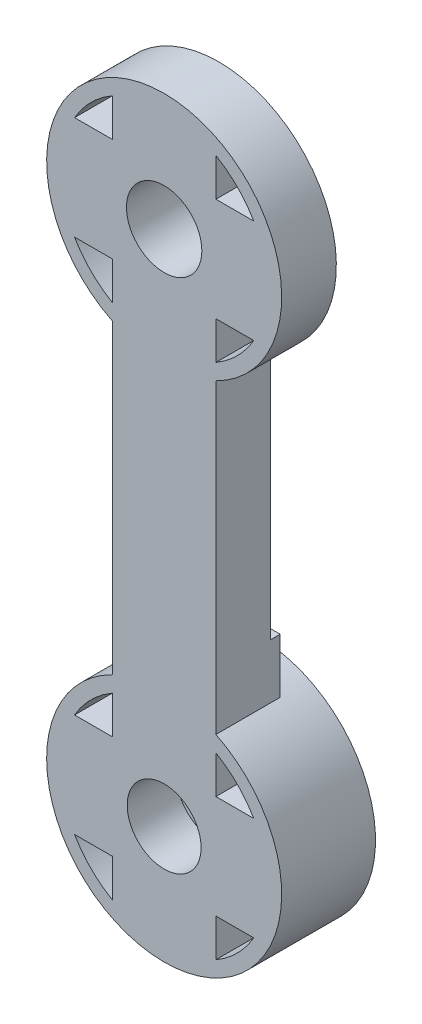
from build123d import *
from build123d.topology import SkipClean

# Parameters (mm, degrees)
SKETCH1_R               = 3.5
SKETCH1_R_2             = 1.5
BOSS_EXTRUDE4_DEPTH     = 3
BOSS_EXTRUDE5_START     = 3
SKETCH3_R               = 1.5
BOSS_EXTRUDE5_DEPTH     = 3
SKETCH4_R               = 2.5
CUT_EXTRUDE1_DEPTH      = 1.5
SKETCH5_R               = 7
CUT_EXTRUDE2_DEPTH      = 2
SKETCH6_R               = 7.95
CUT_EXTRUDE3_DEPTH      = 1
SKETCH7_R               = 2.5
CUT_EXTRUDE4_DEPTH      = 1.85
BOSS_EXTRUDE6_START     = 0.7
SKETCH8_R               = 7.95
SKETCH8_R_2             = 7
BOSS_EXTRUDE6_DEPTH     = 0.7
BOSS_EXTRUDE8_START     = 0.7
SKETCH9_R               = 7.95
SKETCH9_R_2             = 1.5
BOSS_EXTRUDE8_DEPTH     = 0.7
BOSS_EXTRUDE9_START     = 0.7
BOSS_EXTRUDE9_DEPTH     = 0.7
CUT_EXTRUDE5_DEPTH      = 45.603755447
CUT_EXTRUDE5_DEPTH_BACK = 45.603755447
SKETCH11_W              = 3
SKETCH11_H              = 15.9
SKETCH11_W_2            = 2
BOSS_EXTRUDE10_START    = 0.65
BOSS_EXTRUDE10_DEPTH    = 0.65
BOSS_EXTRUDE11_START    = 2.65
SKETCH13_R              = 1.5
BOSS_EXTRUDE11_DEPTH    = 2.65
SKETCH14_R              = 2.55
CUT_EXTRUDE6_DEPTH      = 45.138730158


with BuildPart() as part:
    # Sketch1 → Boss-Extrude4 (new body)
    # profile 1 of 34: a face of its own
    with BuildSketch(Plane.XY):
        with BuildLine():
            Line((-3.5, 3.5), (0, 3.5))
            Line((0, 3.5), (3.5, 3.5))
            Line((3.5, 3.5), (3.5, 6.062177826))
            ThreePointArc((3.5, 6.062177826), (0, 7), (-3.5, 6.062177826))
            Line((-3.5, 6.062177826), (-3.5, 3.5))
        make_face()
    # profile 2 of 34: a face of its own
    with BuildSketch(Plane.XY):
        with BuildLine():
            ThreePointArc((3.5, 6.062177826), (4.949747468, 4.949747468), (6.062177826, 3.5))
            Line((6.062177826, 3.5), (7.138101989, 3.5))
            ThreePointArc((7.138101989, 3.5), (0, 7.95), (-7.138101989, 3.5))
            Line((-7.138101989, 3.5), (-6.062177826, 3.5))
            ThreePointArc((-6.062177826, 3.5), (-4.949747468, 4.949747468), (-3.5, 6.062177826))
            ThreePointArc((-3.5, 6.062177826), (0, 7), (3.5, 6.062177826))
        make_face()
    # profile 3 of 34: a face of its own
    with BuildSketch(Plane.XY):
        with BuildLine():
            Line((3.5, -27.861898011), (3.5, -7.138101989))
            ThreePointArc((3.5, -7.138101989), (0, -7.95), (-3.5, -7.138101989))
            Line((-3.5, -7.138101989), (-3.5, -27.861898011))
            ThreePointArc((-3.5, -27.861898011), (0, -27.05), (3.5, -27.861898011))
        make_face()
    # profile 4 of 34: a face of its own
    with BuildSketch(Plane.XY):
        with BuildLine():
            Line((-6.062177826, -38.5), (-7.138101989, -38.5))
            ThreePointArc((-7.138101989, -38.5), (0, -42.95), (7.138101989, -38.5))
            Line((7.138101989, -38.5), (6.062177826, -38.5))
            ThreePointArc((6.062177826, -38.5), (4.949747468, -39.949747468), (3.5, -41.062177826))
            ThreePointArc((3.5, -41.062177826), (0, -42), (-3.5, -41.062177826))
            ThreePointArc((-3.5, -41.062177826), (-4.949747468, -39.949747468), (-6.062177826, -38.5))
        make_face()
    # profile 5 of 34: a face of its own
    with BuildSketch(Plane.XY):
        with BuildLine():
            Line((3.5, -41.062177826), (3.5, -38.5))
            Line((3.5, -38.5), (0, -38.5))
            Line((0, -38.5), (-3.5, -38.5))
            Line((-3.5, -38.5), (-3.5, -41.062177826))
            ThreePointArc((-3.5, -41.062177826), (0, -42), (3.5, -41.062177826))
        make_face()
    # profile 6 of 34: a face of its own
    with BuildSketch(Plane.XY):
        with BuildLine():
            ThreePointArc((7.95, -35), (7.744366043, -33.203532746), (7.138101989, -31.5))
            Line((7.138101989, -31.5), (6.062177826, -31.5))
            ThreePointArc((6.062177826, -31.5), (6.761480784, -33.188266684), (7, -35))
            ThreePointArc((7, -35), (6.761480784, -36.811733316), (6.062177826, -38.5))
            Line((6.062177826, -38.5), (7.138101989, -38.5))
            ThreePointArc((7.138101989, -38.5), (7.744366043, -36.796467254), (7.95, -35))
        make_face()
    # profile 7 of 34: a face of its own
    with BuildSketch(Plane.XY):
        with BuildLine():
            Line((-6.062177826, -31.5), (-7.138101989, -31.5))
            ThreePointArc((-7.138101989, -31.5), (-7.95, -35), (-7.138101989, -38.5))
            Line((-7.138101989, -38.5), (-6.062177826, -38.5))
            ThreePointArc((-6.062177826, -38.5), (-7, -35), (-6.062177826, -31.5))
        make_face()
    # profile 8 of 34: a face of its own
    with BuildSketch(Plane.XY):
        with BuildLine():
            Line((3.5, -38.5), (3.5, -35))
            ThreePointArc((3.5, -35), (2.474873734, -37.474873734), (0, -38.5))
            Line((0, -38.5), (3.5, -38.5))
        make_face()
    # profile 9 of 34: a face of its own
    with BuildSketch(Plane.XY):
        with BuildLine():
            ThreePointArc((0, -38.5), (-2.474873734, -37.474873734), (-3.5, -35))
            Line((-3.5, -35), (-3.5, -38.5))
            Line((-3.5, -38.5), (0, -38.5))
        make_face()
    # profile 10 of 34: a face of its own
    with BuildSketch(Plane.XY):
        with BuildLine():
            ThreePointArc((7.95, -35), (7.744366043, -33.203532746), (7.138101989, -31.5))
            Line((7.138101989, -31.5), (6.062177826, -31.5))
            ThreePointArc((6.062177826, -31.5), (6.761480784, -33.188266684), (7, -35))
            ThreePointArc((7, -35), (6.761480784, -36.811733316), (6.062177826, -38.5))
            Line((6.062177826, -38.5), (7.138101989, -38.5))
            ThreePointArc((7.138101989, -38.5), (7.744366043, -36.796467254), (7.95, -35))
        make_face()
    # profile 11 of 34: a face of its own
    with BuildSketch(Plane.XY):
        with BuildLine():
            Line((-6.062177826, -31.5), (-7.138101989, -31.5))
            ThreePointArc((-7.138101989, -31.5), (-7.95, -35), (-7.138101989, -38.5))
            Line((-7.138101989, -38.5), (-6.062177826, -38.5))
            ThreePointArc((-6.062177826, -38.5), (-7, -35), (-6.062177826, -31.5))
        make_face()
    # profile 12 of 34: a face of its own
    with BuildSketch(Plane.XY):
        with Locations((0, -35)):
            Circle(SKETCH1_R)
        with Locations((0, -35)):
            Circle(SKETCH1_R_2, mode=Mode.SUBTRACT)
    # profile 13 of 34: a face of its own
    with BuildSketch(Plane.XY):
        with BuildLine():
            Line((0, -31.5), (-3.5, -31.5))
            Line((-3.5, -31.5), (-3.5, -35))
            ThreePointArc((-3.5, -35), (-2.474873734, -32.525126266), (0, -31.5))
        make_face()
    # profile 14 of 34: a face of its own
    with BuildSketch(Plane.XY):
        with BuildLine():
            Line((3.5, -35), (3.5, -31.5))
            Line((3.5, -31.5), (0, -31.5))
            ThreePointArc((0, -31.5), (2.474873734, -32.525126266), (3.5, -35))
        make_face()
    # profile 15 of 34: a face of its own
    with BuildSketch(Plane.XY):
        with BuildLine():
            Line((3.5, -31.5), (3.5, -28.937822174))
            ThreePointArc((3.5, -28.937822174), (0, -28), (-3.5, -28.937822174))
            Line((-3.5, -28.937822174), (-3.5, -31.5))
            Line((-3.5, -31.5), (0, -31.5))
            Line((0, -31.5), (3.5, -31.5))
        make_face()
    # profile 16 of 34: a face of its own
    with BuildSketch(Plane.XY):
        with BuildLine():
            Line((-3.5, -28.937822174), (-3.5, -27.861898011))
            ThreePointArc((-3.5, -27.861898011), (-5.62149891, -29.37850109), (-7.138101989, -31.5))
            Line((-7.138101989, -31.5), (-6.062177826, -31.5))
            ThreePointArc((-6.062177826, -31.5), (-4.949747468, -30.050252532), (-3.5, -28.937822174))
        make_face()
    # profile 17 of 34: a face of its own
    with BuildSketch(Plane.XY):
        with BuildLine():
            ThreePointArc((7.138101989, -31.5), (5.62149891, -29.37850109), (3.5, -27.861898011))
            Line((3.5, -27.861898011), (3.5, -28.937822174))
            ThreePointArc((3.5, -28.937822174), (4.949747468, -30.050252532), (6.062177826, -31.5))
            Line((6.062177826, -31.5), (7.138101989, -31.5))
        make_face()
    # profile 18 of 34: a face of its own
    with BuildSketch(Plane.XY):
        with BuildLine():
            Line((3.5, -28.937822174), (3.5, -27.861898011))
            ThreePointArc((3.5, -27.861898011), (0, -27.05), (-3.5, -27.861898011))
            Line((-3.5, -27.861898011), (-3.5, -28.937822174))
            ThreePointArc((-3.5, -28.937822174), (0, -28), (3.5, -28.937822174))
        make_face()
    # profile 19 of 34: a face of its own
    with BuildSketch(Plane.XY):
        with BuildLine():
            Line((-3.5, -35), (-3.5, -31.5))
            Line((-3.5, -31.5), (-6.062177826, -31.5))
            ThreePointArc((-6.062177826, -31.5), (-7, -35), (-6.062177826, -38.5))
            Line((-6.062177826, -38.5), (-3.5, -38.5))
            Line((-3.5, -38.5), (-3.5, -35))
        make_face()
    # profile 20 of 34: a face of its own
    with BuildSketch(Plane.XY):
        with BuildLine():
            Line((6.062177826, -31.5), (3.5, -31.5))
            Line((3.5, -31.5), (3.5, -35))
            Line((3.5, -35), (3.5, -38.5))
            Line((3.5, -38.5), (6.062177826, -38.5))
            ThreePointArc((6.062177826, -38.5), (6.761480784, -36.811733316), (7, -35))
            ThreePointArc((7, -35), (6.761480784, -33.188266684), (6.062177826, -31.5))
        make_face()
    # profile 21 of 34: a face of its own
    with BuildSketch(Plane.XY):
        with BuildLine():
            Line((3.5, -6.062177826), (3.5, -3.5))
            Line((3.5, -3.5), (0, -3.5))
            Line((0, -3.5), (-3.5, -3.5))
            Line((-3.5, -3.5), (-3.5, -6.062177826))
            ThreePointArc((-3.5, -6.062177826), (0, -7), (3.5, -6.062177826))
        make_face()
    # profile 22 of 34: a face of its own
    with BuildSketch(Plane.XY):
        with BuildLine():
            Line((3.5, -7.138101989), (3.5, -6.062177826))
            ThreePointArc((3.5, -6.062177826), (0, -7), (-3.5, -6.062177826))
            Line((-3.5, -6.062177826), (-3.5, -7.138101989))
            ThreePointArc((-3.5, -7.138101989), (0, -7.95), (3.5, -7.138101989))
        make_face()
    # profile 23 of 34: a face of its own
    with BuildSketch(Plane.XY):
        with BuildLine():
            Line((7.138101989, -3.5), (6.062177826, -3.5))
            ThreePointArc((6.062177826, -3.5), (4.949747468, -4.949747468), (3.5, -6.062177826))
            Line((3.5, -6.062177826), (3.5, -7.138101989))
            ThreePointArc((3.5, -7.138101989), (5.62149891, -5.62149891), (7.138101989, -3.5))
        make_face()
    # profile 24 of 34: a face of its own
    with BuildSketch(Plane.XY):
        with BuildLine():
            Line((7.138101989, 3.5), (6.062177826, 3.5))
            ThreePointArc((6.062177826, 3.5), (6.761480784, 1.811733316), (7, 0))
            ThreePointArc((7, 0), (6.761480784, -1.811733316), (6.062177826, -3.5))
            Line((6.062177826, -3.5), (7.138101989, -3.5))
            ThreePointArc((7.138101989, -3.5), (7.744366043, -1.796467254), (7.95, 0))
            ThreePointArc((7.95, 0), (7.744366043, 1.796467254), (7.138101989, 3.5))
        make_face()
    # profile 25 of 34: a face of its own
    with BuildSketch(Plane.XY):
        with BuildLine():
            Line((7.138101989, 3.5), (6.062177826, 3.5))
            ThreePointArc((6.062177826, 3.5), (6.761480784, 1.811733316), (7, 0))
            ThreePointArc((7, 0), (6.761480784, -1.811733316), (6.062177826, -3.5))
            Line((6.062177826, -3.5), (7.138101989, -3.5))
            ThreePointArc((7.138101989, -3.5), (7.744366043, -1.796467254), (7.95, 0))
            ThreePointArc((7.95, 0), (7.744366043, 1.796467254), (7.138101989, 3.5))
        make_face()
    # profile 26 of 34: a face of its own
    with BuildSketch(Plane.XY):
        with BuildLine():
            ThreePointArc((-6.062177826, -3.5), (-7, 0), (-6.062177826, 3.5))
            Line((-6.062177826, 3.5), (-7.138101989, 3.5))
            ThreePointArc((-7.138101989, 3.5), (-7.95, 0), (-7.138101989, -3.5))
            Line((-7.138101989, -3.5), (-6.062177826, -3.5))
        make_face()
    # profile 27 of 34: a face of its own
    with BuildSketch(Plane.XY):
        with BuildLine():
            ThreePointArc((-3.5, -6.062177826), (-4.949747468, -4.949747468), (-6.062177826, -3.5))
            Line((-6.062177826, -3.5), (-7.138101989, -3.5))
            ThreePointArc((-7.138101989, -3.5), (-5.62149891, -5.62149891), (-3.5, -7.138101989))
            Line((-3.5, -7.138101989), (-3.5, -6.062177826))
        make_face()
    # profile 28 of 34: a face of its own
    with BuildSketch(Plane.XY):
        with BuildLine():
            Line((-3.5, 0), (-3.5, 3.5))
            Line((-3.5, 3.5), (-6.062177826, 3.5))
            ThreePointArc((-6.062177826, 3.5), (-7, 0), (-6.062177826, -3.5))
            Line((-6.062177826, -3.5), (-3.5, -3.5))
            Line((-3.5, -3.5), (-3.5, 0))
        make_face()
    # profile 29 of 34: a face of its own
    with BuildSketch(Plane.XY):
        with BuildLine():
            Line((6.062177826, 3.5), (3.5, 3.5))
            Line((3.5, 3.5), (3.5, 0))
            Line((3.5, 0), (3.5, -3.5))
            Line((3.5, -3.5), (6.062177826, -3.5))
            ThreePointArc((6.062177826, -3.5), (6.761480784, -1.811733316), (7, 0))
            ThreePointArc((7, 0), (6.761480784, 1.811733316), (6.062177826, 3.5))
        make_face()
    # profile 30 of 34: a face of its own
    with BuildSketch(Plane.XY):
        with BuildLine():
            Line((3.5, -3.5), (3.5, 0))
            ThreePointArc((3.5, 0), (2.474873734, -2.474873734), (0, -3.5))
            Line((0, -3.5), (3.5, -3.5))
        make_face()
    # profile 31 of 34: a face of its own
    with BuildSketch(Plane.XY):
        Circle(SKETCH1_R)
        Circle(SKETCH1_R_2, mode=Mode.SUBTRACT)
    # profile 32 of 34: a face of its own
    with BuildSketch(Plane.XY):
        with BuildLine():
            ThreePointArc((0, -3.5), (-2.474873734, -2.474873734), (-3.5, 0))
            Line((-3.5, 0), (-3.5, -3.5))
            Line((-3.5, -3.5), (0, -3.5))
        make_face()
    # profile 33 of 34: a face of its own
    with BuildSketch(Plane.XY):
        with BuildLine():
            ThreePointArc((-3.5, 0), (-2.474873734, 2.474873734), (0, 3.5))
            Line((0, 3.5), (-3.5, 3.5))
            Line((-3.5, 3.5), (-3.5, 0))
        make_face()
    # profile 34 of 34: a face of its own
    with BuildSketch(Plane.XY):
        with BuildLine():
            Line((3.5, 3.5), (0, 3.5))
            ThreePointArc((0, 3.5), (2.474873734, 2.474873734), (3.5, 0))
            Line((3.5, 0), (3.5, 3.5))
        make_face()
    extrude(amount=BOSS_EXTRUDE4_DEPTH)

    # Sketch3 → Boss-Extrude5 (add)
    # profile 1 of 4: a face of its own
    with SkipClean():  # the faces are left unmerged after this step: merging them gives an invalid solid
        with BuildSketch(Plane(origin=(0, 0, 0), x_dir=(-1, 0, 0), z_dir=(0, 0, -1)).offset(BOSS_EXTRUDE5_START)):
            with BuildLine():
                ThreePointArc((3.5, -7.138101989), (6.746387922, -4.205799567), (7.95, 0))
                ThreePointArc((7.95, 0), (-4.205799567, 6.746387922), (-3.5, -7.138101989))
                ThreePointArc((-3.5, -7.138101989), (0, -7.95), (3.5, -7.138101989))
            make_face()
            with BuildLine():
                ThreePointArc((-6.062177826, 3.5), (-4.949747468, 4.949747468), (-3.5, 6.062177826))
                ThreePointArc((-3.5, 6.062177826), (0, 7), (3.5, 6.062177826))
                ThreePointArc((3.5, 6.062177826), (4.949747468, 4.949747468), (6.062177826, 3.5))
                ThreePointArc((6.062177826, 3.5), (6.761480784, 1.811733316), (7, 0))
                ThreePointArc((7, 0), (6.761480784, -1.811733316), (6.062177826, -3.5))
                ThreePointArc((6.062177826, -3.5), (4.949747468, -4.949747468), (3.5, -6.062177826))
                ThreePointArc((3.5, -6.062177826), (0, -7), (-3.5, -6.062177826))
                ThreePointArc((-3.5, -6.062177826), (-4.949747468, -4.949747468), (-6.062177826, -3.5))
                ThreePointArc((-6.062177826, -3.5), (-7, 0), (-6.062177826, 3.5))
            make_face(mode=Mode.SUBTRACT)
        # profile 2 of 4: a face of its own
        with BuildSketch(Plane(origin=(0, 0, 0), x_dir=(-1, 0, 0), z_dir=(0, 0, -1)).offset(BOSS_EXTRUDE5_START)):
            with BuildLine():
                ThreePointArc((3.5, 6.062177826), (0, 7), (-3.5, 6.062177826))
                Line((-3.5, 6.062177826), (-3.5, 3.5))
                Line((-3.5, 3.5), (-6.062177826, 3.5))
                ThreePointArc((-6.062177826, 3.5), (-7, 0), (-6.062177826, -3.5))
                Line((-6.062177826, -3.5), (-3.5, -3.5))
                Line((-3.5, -3.5), (-3.5, -6.062177826))
                ThreePointArc((-3.5, -6.062177826), (0, -7), (3.5, -6.062177826))
                Line((3.5, -6.062177826), (3.5, -3.5))
                Line((3.5, -3.5), (6.062177826, -3.5))
                ThreePointArc((6.062177826, -3.5), (6.761480784, -1.811733316), (7, 0))
                ThreePointArc((7, 0), (6.761480784, 1.811733316), (6.062177826, 3.5))
                Line((6.062177826, 3.5), (3.5, 3.5))
                Line((3.5, 3.5), (3.5, 6.062177826))
            make_face()
            Circle(SKETCH3_R, mode=Mode.SUBTRACT)
        # profile 3 of 4: a face of its own
        with BuildSketch(Plane(origin=(0, 0, 0), x_dir=(-1, 0, 0), z_dir=(0, 0, -1)).offset(BOSS_EXTRUDE5_START)):
            with BuildLine():
                ThreePointArc((-3.5, -27.861898011), (-4.205799567, -41.746387922), (7.95, -35))
                ThreePointArc((7.95, -35), (6.746387922, -30.794200433), (3.5, -27.861898011))
                ThreePointArc((3.5, -27.861898011), (0, -27.05), (-3.5, -27.861898011))
            make_face()
            with BuildLine():
                ThreePointArc((6.062177826, -38.5), (4.949747468, -39.949747468), (3.5, -41.062177826))
                ThreePointArc((3.5, -41.062177826), (0, -42), (-3.5, -41.062177826))
                ThreePointArc((-3.5, -41.062177826), (-4.949747468, -39.949747468), (-6.062177826, -38.5))
                ThreePointArc((-6.062177826, -38.5), (-7, -35), (-6.062177826, -31.5))
                ThreePointArc((-6.062177826, -31.5), (-4.949747468, -30.050252532), (-3.5, -28.937822174))
                ThreePointArc((-3.5, -28.937822174), (0, -28), (3.5, -28.937822174))
                ThreePointArc((3.5, -28.937822174), (4.949747468, -30.050252532), (6.062177826, -31.5))
                ThreePointArc((6.062177826, -31.5), (6.761480784, -33.188266684), (7, -35))
                ThreePointArc((7, -35), (6.761480784, -36.811733316), (6.062177826, -38.5))
            make_face(mode=Mode.SUBTRACT)
        # profile 4 of 4: a face of its own
        with BuildSketch(Plane(origin=(0, 0, 0), x_dir=(-1, 0, 0), z_dir=(0, 0, -1)).offset(BOSS_EXTRUDE5_START)):
            with BuildLine():
                ThreePointArc((-3.5, -41.062177826), (0, -42), (3.5, -41.062177826))
                Line((3.5, -41.062177826), (3.5, -38.5))
                Line((3.5, -38.5), (6.062177826, -38.5))
                ThreePointArc((6.062177826, -38.5), (6.761480784, -36.811733316), (7, -35))
                ThreePointArc((7, -35), (6.761480784, -33.188266684), (6.062177826, -31.5))
                Line((6.062177826, -31.5), (3.5, -31.5))
                Line((3.5, -31.5), (3.5, -28.937822174))
                ThreePointArc((3.5, -28.937822174), (0, -28), (-3.5, -28.937822174))
                Line((-3.5, -28.937822174), (-3.5, -31.5))
                Line((-3.5, -31.5), (-6.062177826, -31.5))
                ThreePointArc((-6.062177826, -31.5), (-7, -35), (-6.062177826, -38.5))
                Line((-6.062177826, -38.5), (-3.5, -38.5))
                Line((-3.5, -38.5), (-3.5, -41.062177826))
            make_face()
            with Locations((0, -35)):
                Circle(SKETCH3_R, mode=Mode.SUBTRACT)
        extrude(amount=-BOSS_EXTRUDE5_DEPTH)

    # Sketch4 → Cut-Extrude1 (cut)
    with SkipClean():  # the faces are left unmerged after this step: merging them gives an invalid solid
        with BuildSketch(Plane.XY.offset(3)):
            with Locations((0, -35)):
                Circle(SKETCH4_R)
            with Locations(Location((0, 0, 0), (0, 0, 180))):
                Circle(SKETCH4_R)
        extrude(amount=-CUT_EXTRUDE1_DEPTH, mode=Mode.SUBTRACT)

    # Sketch5 → Cut-Extrude2 (cut)
    with SkipClean():  # the faces are left unmerged after this step: merging them gives an invalid solid
        with BuildSketch(Plane(origin=(0, 0, -3), x_dir=(-1, 0, 0), z_dir=(0, 0, -1))):
            Circle(SKETCH5_R)
        extrude(amount=-CUT_EXTRUDE2_DEPTH, mode=Mode.SUBTRACT)

    # Sketch6 → Cut-Extrude3 (cut)
    with SkipClean():  # the faces are left unmerged after this step: merging them gives an invalid solid
        with BuildSketch(Plane(origin=(0, 0, -3), x_dir=(-1, 0, 0), z_dir=(0, 0, -1))):
            with Locations((0, -35)):
                Circle(SKETCH6_R)
        extrude(amount=-CUT_EXTRUDE3_DEPTH, mode=Mode.SUBTRACT)

    # Sketch7 → Cut-Extrude4 (cut)
    with SkipClean():  # the faces are left unmerged after this step: merging them gives an invalid solid
        with BuildSketch(Plane.XY.offset(1.5)):
            with Locations((0, -35)):
                Circle(SKETCH7_R)
        extrude(amount=-CUT_EXTRUDE4_DEPTH, mode=Mode.SUBTRACT)

    # Sketch8 → Boss-Extrude6 (add)
    with SkipClean():  # the faces are left unmerged after this step: merging them gives an invalid solid
        with BuildSketch(Plane(origin=(0, 0, -3), x_dir=(-1, 0, 0), z_dir=(0, 0, -1)).offset(BOSS_EXTRUDE6_START)):
            Circle(SKETCH8_R)
            Circle(SKETCH8_R_2, mode=Mode.SUBTRACT)
        extrude(amount=-BOSS_EXTRUDE6_DEPTH)

    # Sketch9 → Boss-Extrude8 (add)
    # profile 1 of 2: a face of its own
    with SkipClean():  # the faces are left unmerged after this step: merging them gives an invalid solid
        with BuildSketch(Plane(origin=(0, 0, -2), x_dir=(-1, 0, 0), z_dir=(0, 0, -1)).offset(BOSS_EXTRUDE8_START)):
            with Locations((0, -35)):
                Circle(SKETCH9_R)
            with BuildLine():
                ThreePointArc((-6.062177826, -31.5), (-4.949747468, -30.050252532), (-3.5, -28.937822174))
                ThreePointArc((-3.5, -28.937822174), (0, -28), (3.5, -28.937822174))
                ThreePointArc((3.5, -28.937822174), (4.949747468, -30.050252532), (6.062177826, -31.5))
                ThreePointArc((6.062177826, -31.5), (6.761480784, -33.188266684), (7, -35))
                ThreePointArc((7, -35), (6.761480784, -36.811733316), (6.062177826, -38.5))
                ThreePointArc((6.062177826, -38.5), (4.949747468, -39.949747468), (3.5, -41.062177826))
                ThreePointArc((3.5, -41.062177826), (0, -42), (-3.5, -41.062177826))
                ThreePointArc((-3.5, -41.062177826), (-4.949747468, -39.949747468), (-6.062177826, -38.5))
                ThreePointArc((-6.062177826, -38.5), (-7, -35), (-6.062177826, -31.5))
            make_face(mode=Mode.SUBTRACT)
        # profile 2 of 2: a face of its own
        with BuildSketch(Plane(origin=(0, 0, -2), x_dir=(-1, 0, 0), z_dir=(0, 0, -1)).offset(BOSS_EXTRUDE8_START)):
            with BuildLine():
                ThreePointArc((3.5, -28.937822174), (0, -28), (-3.5, -28.937822174))
                Line((-3.5, -28.937822174), (-3.5, -31.5))
                Line((-3.5, -31.5), (-6.062177826, -31.5))
                ThreePointArc((-6.062177826, -31.5), (-7, -35), (-6.062177826, -38.5))
                Line((-6.062177826, -38.5), (-3.5, -38.5))
                Line((-3.5, -38.5), (-3.5, -41.062177826))
                ThreePointArc((-3.5, -41.062177826), (0, -42), (3.5, -41.062177826))
                Line((3.5, -41.062177826), (3.5, -38.5))
                Line((3.5, -38.5), (6.062177826, -38.5))
                ThreePointArc((6.062177826, -38.5), (6.761480784, -36.811733316), (7, -35))
                ThreePointArc((7, -35), (6.761480784, -33.188266684), (6.062177826, -31.5))
                Line((6.062177826, -31.5), (3.5, -31.5))
                Line((3.5, -31.5), (3.5, -28.937822174))
            make_face()
            with Locations((0, -35)):
                Circle(SKETCH9_R_2, mode=Mode.SUBTRACT)
        extrude(amount=-BOSS_EXTRUDE8_DEPTH)

    # Sketch10 → Boss-Extrude9 (add)
    with SkipClean():  # the faces are left unmerged after this step: merging them gives an invalid solid
        with BuildSketch(Plane(origin=(0, 0, 0), x_dir=(-1, 0, 0), z_dir=(0, 0, -1)).offset(BOSS_EXTRUDE9_START)):
            with BuildLine():
                ThreePointArc((3.5, -7.138101989), (0, -7.95), (-3.5, -7.138101989))
                Line((-3.5, -7.138101989), (-3.5, -27.861898011))
                ThreePointArc((-3.5, -27.861898011), (0, -27.05), (3.5, -27.861898011))
                Line((3.5, -27.861898011), (3.5, -7.138101989))
            make_face()
        extrude(amount=-BOSS_EXTRUDE9_DEPTH)

    # Sketch11 → Cut-Extrude5 (cut, two sides: drawn at the far end of the back side and taken through both)
    with SkipClean():  # the faces are left unmerged after this step: merging them gives an invalid solid
        with BuildSketch(Plane(origin=(3.5, 0, 0), x_dir=(0, 0, -1), z_dir=(1, 0, 0)).offset(-CUT_EXTRUDE5_DEPTH_BACK)):
            with Locations((2.2, 0)):
                Rectangle(SKETCH11_W, SKETCH11_H)
            with Locations((1.7, -35)):
                Rectangle(SKETCH11_W_2, SKETCH11_H)
        extrude(amount=CUT_EXTRUDE5_DEPTH + CUT_EXTRUDE5_DEPTH_BACK, mode=Mode.SUBTRACT)

    # Sketch12 → Boss-Extrude10 (add)
    with SkipClean():  # the faces are left unmerged after this step: merging them gives an invalid solid
        with BuildSketch(Plane(origin=(0, 0, -0.7), x_dir=(-1, 0, 0), z_dir=(0, 0, -1)).offset(BOSS_EXTRUDE10_START)):
            with BuildLine():
                Line((-3.5, -24.161898011), (-3.5, -27.861898011))
                ThreePointArc((-3.5, -27.861898011), (0, -27.05), (3.5, -27.861898011))
                Line((3.5, -27.861898011), (3.5, -24.161898011))
                Line((3.5, -24.161898011), (-3.5, -24.161898011))
            make_face()
        extrude(amount=-BOSS_EXTRUDE10_DEPTH)

    # Sketch13 → Boss-Extrude11 (add)
    # profile 1 of 2: a face of its own
    with SkipClean():  # the faces are left unmerged after this step: merging them gives an invalid solid
        with BuildSketch(Plane(origin=(0, 0, -0.7), x_dir=(-1, 0, 0), z_dir=(0, 0, -1)).offset(BOSS_EXTRUDE11_START)):
            with BuildLine():
                ThreePointArc((-3.5, -27.861898011), (-4.205799567, -41.746387922), (7.95, -35))
                ThreePointArc((7.95, -35), (6.746387922, -30.794200433), (3.5, -27.861898011))
                ThreePointArc((3.5, -27.861898011), (0, -27.05), (-3.5, -27.861898011))
            make_face()
            with BuildLine():
                ThreePointArc((-6.062177826, -38.5), (-7, -35), (-6.062177826, -31.5))
                ThreePointArc((-6.062177826, -31.5), (-4.949747468, -30.050252532), (-3.5, -28.937822174))
                ThreePointArc((-3.5, -28.937822174), (0, -28), (3.5, -28.937822174))
                ThreePointArc((3.5, -28.937822174), (4.949747468, -30.050252532), (6.062177826, -31.5))
                ThreePointArc((6.062177826, -31.5), (6.761480784, -33.188266684), (7, -35))
                ThreePointArc((7, -35), (6.761480784, -36.811733316), (6.062177826, -38.5))
                ThreePointArc((6.062177826, -38.5), (4.949747468, -39.949747468), (3.5, -41.062177826))
                ThreePointArc((3.5, -41.062177826), (0, -42), (-3.5, -41.062177826))
                ThreePointArc((-3.5, -41.062177826), (-4.949747468, -39.949747468), (-6.062177826, -38.5))
            make_face(mode=Mode.SUBTRACT)
        # profile 2 of 2: a face of its own
        with BuildSketch(Plane(origin=(0, 0, -0.7), x_dir=(-1, 0, 0), z_dir=(0, 0, -1)).offset(BOSS_EXTRUDE11_START)):
            with BuildLine():
                Line((-3.5, -31.5), (-6.062177826, -31.5))
                ThreePointArc((-6.062177826, -31.5), (-7, -35), (-6.062177826, -38.5))
                Line((-6.062177826, -38.5), (-3.5, -38.5))
                Line((-3.5, -38.5), (-3.5, -41.062177826))
                ThreePointArc((-3.5, -41.062177826), (0, -42), (3.5, -41.062177826))
                Line((3.5, -41.062177826), (3.5, -38.5))
                Line((3.5, -38.5), (6.062177826, -38.5))
                ThreePointArc((6.062177826, -38.5), (6.761480784, -36.811733316), (7, -35))
                ThreePointArc((7, -35), (6.761480784, -33.188266684), (6.062177826, -31.5))
                Line((6.062177826, -31.5), (3.5, -31.5))
                Line((3.5, -31.5), (3.5, -28.937822174))
                ThreePointArc((3.5, -28.937822174), (0, -28), (-3.5, -28.937822174))
                Line((-3.5, -28.937822174), (-3.5, -31.5))
            make_face()
            with Locations((0, -35)):
                Circle(SKETCH13_R, mode=Mode.SUBTRACT)
        extrude(amount=-BOSS_EXTRUDE11_DEPTH)

    # Sketch14 → Cut-Extrude6 (cut, through all)
    with SkipClean():  # the faces are left unmerged after this step: merging them gives an invalid solid
        with BuildSketch(Plane.XY.offset(3)):
            Circle(SKETCH14_R)
        extrude(amount=-CUT_EXTRUDE6_DEPTH, mode=Mode.SUBTRACT)


solid = part.part
